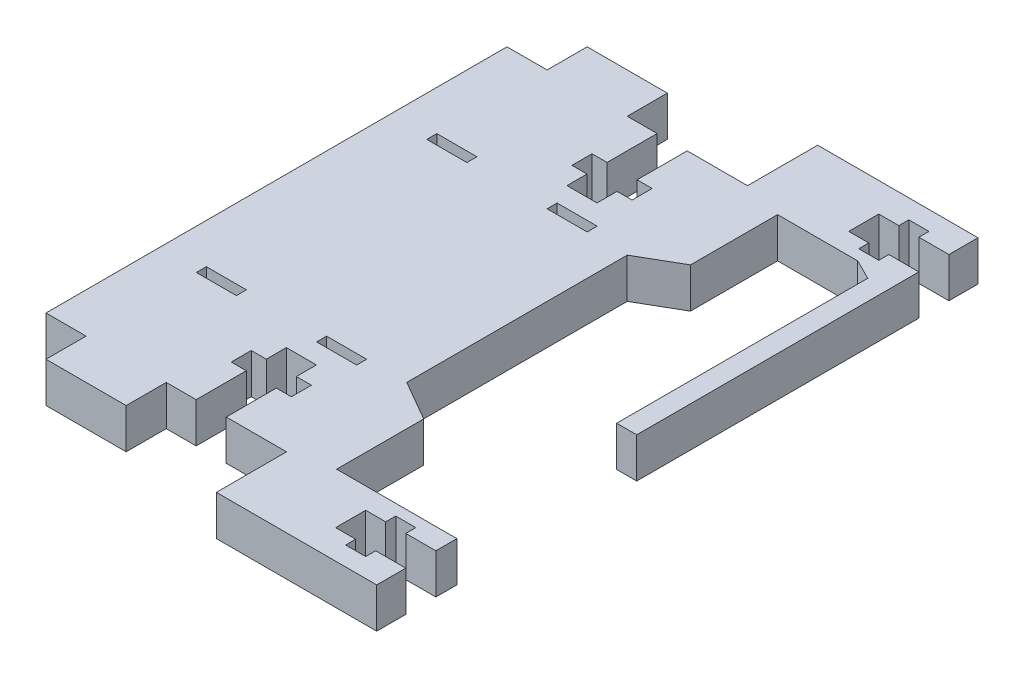
from build123d import *

# Parameters (mm, degrees)
BOSS_EXTRUDE1_DEPTH = 6.35
SKETCH2_W           = 6.35
SKETCH2_H           = 1.5875
CUT_EXTRUDE1_DEPTH  = 6.35
CUT_EXTRUDE2_DEPTH  = 6.35
SKETCH4_W           = 36.519416468
SKETCH4_H           = 95.25
CUT_EXTRUDE5_DEPTH  = 6.35
SKETCH7_W           = 18.153928565
SKETCH7_H           = 28.487742684
CUT_EXTRUDE6_DEPTH  = 6.35


with BuildPart() as part:
    # Sketch1 → Boss-Extrude1 (new body)
    with BuildSketch(Plane(origin=(0, 0, 0), x_dir=(1, 0, 0), z_dir=(0, 1, 0))):
        Polygon((38.1, 65.0875), (66.675, 65.0875), (66.675, -30.1625), (38.1, -30.1625), (38.1, -19.05), (19.05, -19.05), (19.05, -25.4), (6.35, -25.4), (6.35, -19.05), (0, -19.05), (0, 0), (0, 34.925), (0, 53.975), (6.35, 53.975), (6.35, 60.325), (19.05, 60.325), (19.05, 53.975), (38.1, 53.975), align=None)
        Polygon((38.1, 34.925), (44.45, 38.591174209), (44.45, 52.3875), (57.15, 52.3875), (60.325, 50.8), (60.325, -15.875), (57.15, -17.4625), (44.45, -17.4625), (44.45, -3.666174209), (38.1, 0), align=None, mode=Mode.SUBTRACT)
    extrude(amount=BOSS_EXTRUDE1_DEPTH)

    # Sketch2 → Cut-Extrude1 (cut)
    with BuildSketch(Plane(origin=(0, 6.35, 0), x_dir=(1, 0, 0), z_dir=(0, 1, 0))):
        with Locations((9.525, 35.71875)):
            Rectangle(SKETCH2_W, SKETCH2_H)
        with Locations((9.525, -0.79375)):
            Rectangle(SKETCH2_W, SKETCH2_H)
        with Locations((28.575, 35.71875)):
            Rectangle(SKETCH2_W, SKETCH2_H)
        with Locations((28.575, -0.79375)):
            Rectangle(SKETCH2_W, SKETCH2_H)
    extrude(amount=-CUT_EXTRUDE1_DEPTH, mode=Mode.SUBTRACT)

    # Sketch3 → Cut-Extrude2 (cut)
    with BuildSketch(Plane(origin=(0, 6.35, 0), x_dir=(1, 0, 0), z_dir=(0, 1, 0))):
        Polygon((28.549517374, 53.975), (23.787017374, 53.975), (23.787017374, 46.0375), (21.405767374, 46.0375), (21.405767374, 42.8625), (23.787017374, 42.8625), (23.787017374, 39.6875), (28.549517374, 39.6875), (28.549517374, 42.8625), (30.930767374, 42.8625), (30.930767374, 46.0375), (28.549517374, 46.0375), align=None)
        Polygon((66.675, 55.72125), (66.675, 60.48375), (58.7375, 60.48375), (58.7375, 62.07125), (55.5625, 62.07125), (55.5625, 60.48375), (52.3875, 60.48375), (52.3875, 55.72125), (55.5625, 55.72125), (55.5625, 54.13375), (58.7375, 54.13375), (58.7375, 55.72125), align=None)
        Polygon((55.5625, -27.14625), (58.7375, -27.14625), (58.7375, -25.55875), (66.675, -25.55875), (66.675, -20.79625), (58.7375, -20.79625), (58.7375, -19.20875), (55.5625, -19.20875), (55.5625, -20.79625), (52.3875, -20.79625), (52.3875, -25.55875), (55.5625, -25.55875), align=None)
        Polygon((28.549517374, -11.1125), (30.930767374, -11.1125), (30.930767374, -7.9375), (28.549517374, -7.9375), (28.549517374, -4.7625), (23.787017374, -4.7625), (23.787017374, -7.9375), (21.405767374, -7.9375), (21.405767374, -11.1125), (23.787017374, -11.1125), (23.787017374, -19.05), (28.549517374, -19.05), align=None)
    extrude(amount=-CUT_EXTRUDE2_DEPTH, mode=Mode.SUBTRACT)

    # Sketch4 → Cut-Extrude5 (cut)
    with BuildSketch(Plane(origin=(0, 6.35, 0), x_dir=(1, 0, 0), z_dir=(0, 1, 0))):
        with Locations((81.759708234, 17.4625)):
            Rectangle(SKETCH4_W, SKETCH4_H)
    extrude(amount=-CUT_EXTRUDE5_DEPTH, mode=Mode.SUBTRACT)

    # Sketch7 → Cut-Extrude6 (cut)
    with BuildSketch(Plane(origin=(0, 6.35, 0), x_dir=(1, 0, 0), z_dir=(0, 1, 0))):
        with Locations((64.899881691, -3.218628658)):
            Rectangle(SKETCH7_W, SKETCH7_H)
    extrude(amount=-CUT_EXTRUDE6_DEPTH, mode=Mode.SUBTRACT)


solid = part.part
